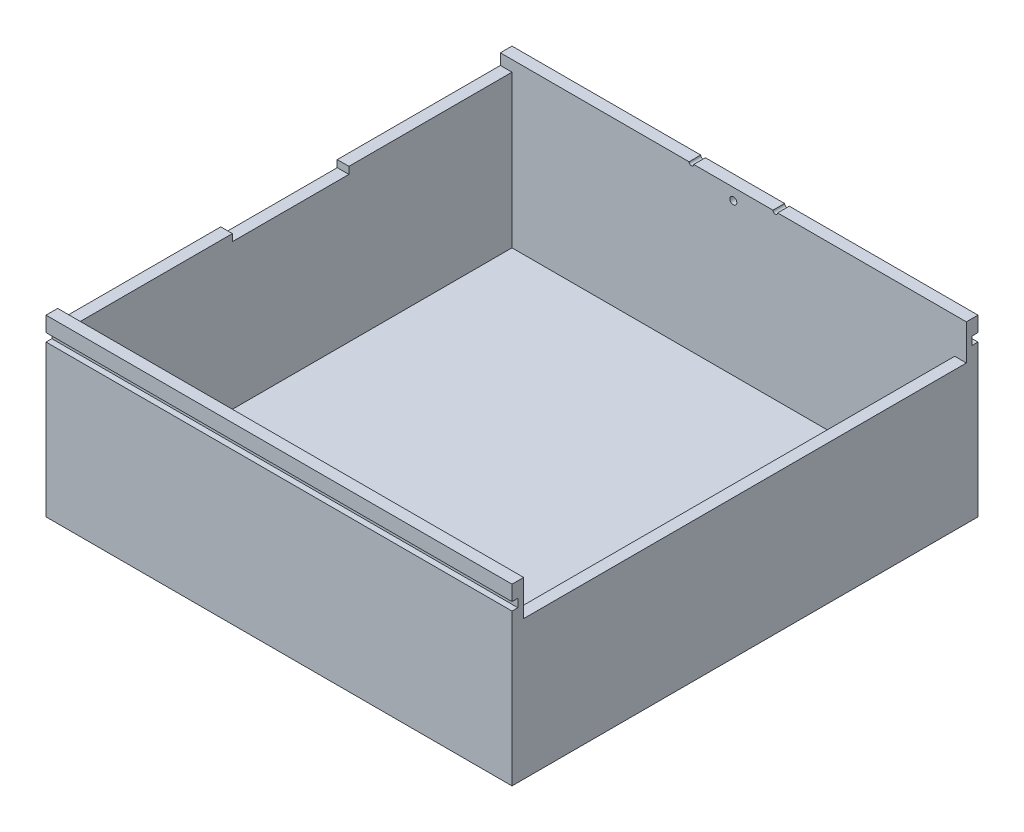
from build123d import *

# Parameters (mm, degrees)
SKETCH_1_W               = 200
SKETCH_1_H               = 200
EXTRUDE_2_DEPTH          = 5
SKETCH_2_W               = 200
SKETCH_2_H               = 5
EXTRUDE_3_DEPTH          = 70
SKETCH_3_W               = 5
SKETCH_3_H               = 190
EXTRUDE_4_DEPTH          = 54.7
SKETCH_4_W               = 200
SKETCH_4_H               = 5
EXTRUDE_5_DEPTH          = 70
SKETCH_14_W              = 5
SKETCH_14_H              = 190
EXTRUDE_7_DEPTH          = 65.3
SKETCH_15_W              = 5
SKETCH_15_H              = 50
CUT_EXTRUDE_7_DEPTH      = 3
CUT_EXTRUDE_8_DEPTH      = 1
CUT_EXTRUDE_8_DEPTH_BACK = 5
CUT_EXTRUDE_9_DEPTH      = 1
CUT_EXTRUDE_9_DEPTH_BACK = 5
SKETCH_19_R              = 1.5
CUT_EXTRUDE_10_DEPTH     = 5
SKETCH_20_W              = 200
SKETCH_20_H              = 3.5
CUT_EXTRUDE_11_DEPTH     = 2.5
SKETCH_21_W              = 82
SKETCH_21_H              = 3.5
CUT_EXTRUDE_13_DEPTH     = 2.5


with BuildPart() as part:
    # Эскиз1 → Бобышка-Вытянуть2 (new body)
    with BuildSketch(Plane(origin=(0, 0, 0), x_dir=(1, 0, 0), z_dir=(0, 1, 0))):
        Rectangle(SKETCH_1_W, SKETCH_1_H)
    extrude(amount=EXTRUDE_2_DEPTH)

    # Эскиз2 → Бобышка-Вытянуть3 (add)
    with BuildSketch(Plane(origin=(0, 5, 0), x_dir=(1, 0, 0), z_dir=(0, 1, 0))):
        with Locations((0, -97.5)):
            Rectangle(SKETCH_2_W, SKETCH_2_H)
    extrude(amount=EXTRUDE_3_DEPTH)

    # Эскиз3 → Бобышка-Вытянуть4 (add)
    with BuildSketch(Plane(origin=(0, 5, 0), x_dir=(1, 0, 0), z_dir=(0, 1, 0))):
        with Locations((97.5, 0)):
            Rectangle(SKETCH_3_W, SKETCH_3_H)
    extrude(amount=EXTRUDE_4_DEPTH)

    # Эскиз4 → Бобышка-Вытянуть5 (add)
    with BuildSketch(Plane(origin=(0, 5, 0), x_dir=(1, 0, 0), z_dir=(0, 1, 0))):
        with Locations((0, 97.5)):
            Rectangle(SKETCH_4_W, SKETCH_4_H)
    extrude(amount=EXTRUDE_5_DEPTH)

    # Эскиз14 → Бобышка-Вытянуть7 (add)
    with BuildSketch(Plane(origin=(0, 5, 0), x_dir=(1, 0, 0), z_dir=(0, 1, 0))):
        with Locations((-97.5, 0)):
            Rectangle(SKETCH_14_W, SKETCH_14_H)
    extrude(amount=EXTRUDE_7_DEPTH)

    # Эскиз15 → Вырез-Вытянуть7 (cut)
    with BuildSketch(Plane(origin=(0, 70.3, 0), x_dir=(1, 0, 0), z_dir=(0, 1, 0))):
        with Locations((-97.5, 0)):
            Rectangle(SKETCH_15_W, SKETCH_15_H)
    extrude(amount=-CUT_EXTRUDE_7_DEPTH, mode=Mode.SUBTRACT)

    # Эскиз16 → Вырез-Вытянуть8 (cut, two sides)
    with BuildSketch(Plane(origin=(0, 0, -100), x_dir=(-1, 0, 0), z_dir=(0, 0, -1))) as cut_extrude_8_sk:
        with BuildLine():
            Line((-19, 366.325434328), (-19, 75))
            ThreePointArc((-19, 75), (-18, 74), (-17, 75))
            Line((-17, 75), (-17, 366.325434328))
            Line((-17, 366.325434328), (-17, 948.976302985))
            Line((-17, 948.976302985), (-19, 948.976302985))
            Line((-19, 948.976302985), (-19, 366.325434328))
        make_face()
    extrude(amount=CUT_EXTRUDE_8_DEPTH, mode=Mode.SUBTRACT)
    extrude(cut_extrude_8_sk.sketch, amount=-CUT_EXTRUDE_8_DEPTH_BACK, mode=Mode.SUBTRACT)

    # Эскиз18 → Вырез-Вытянуть9 (cut, two sides)
    with BuildSketch(Plane(origin=(0, 0, -100), x_dir=(-1, 0, 0), z_dir=(0, 0, -1))) as cut_extrude_9_sk:
        with BuildLine():
            Line((17, 366.325434328), (17, 75))
            ThreePointArc((17, 75), (18, 74), (19, 75))
            Line((19, 75), (19, 366.325434328))
            Line((19, 366.325434328), (19, 948.976302985))
            Line((19, 948.976302985), (17, 948.976302985))
            Line((17, 948.976302985), (17, 366.325434328))
        make_face()
    extrude(amount=CUT_EXTRUDE_9_DEPTH, mode=Mode.SUBTRACT)
    extrude(cut_extrude_9_sk.sketch, amount=-CUT_EXTRUDE_9_DEPTH_BACK, mode=Mode.SUBTRACT)

    # Эскиз19 → Вырез-Вытянуть10 (cut)
    with BuildSketch(Plane(origin=(0, 0, -100), x_dir=(-1, 0, 0), z_dir=(0, 0, -1))):
        with Locations((0, 70)):
            Circle(SKETCH_19_R)
    extrude(amount=-CUT_EXTRUDE_10_DEPTH, mode=Mode.SUBTRACT)

    # Эскиз20 → Вырез-Вытянуть11 (cut)
    with BuildSketch(Plane.XY.offset(100)):
        with Locations((0, 66.75)):
            Rectangle(SKETCH_20_W, SKETCH_20_H)
    extrude(amount=-CUT_EXTRUDE_11_DEPTH, mode=Mode.SUBTRACT)

    # Эскиз21 → Вырез-Вытянуть13 (cut)
    with BuildSketch(Plane(origin=(0, 0, -100), x_dir=(-1, 0, 0), z_dir=(0, 0, -1))):
        with Locations((-59, 66.75)):
            Rectangle(SKETCH_21_W, SKETCH_21_H)
        with Locations((59, 66.75)):
            Rectangle(SKETCH_21_W, SKETCH_21_H)
    extrude(amount=-CUT_EXTRUDE_13_DEPTH, mode=Mode.SUBTRACT)


solid = part.part
